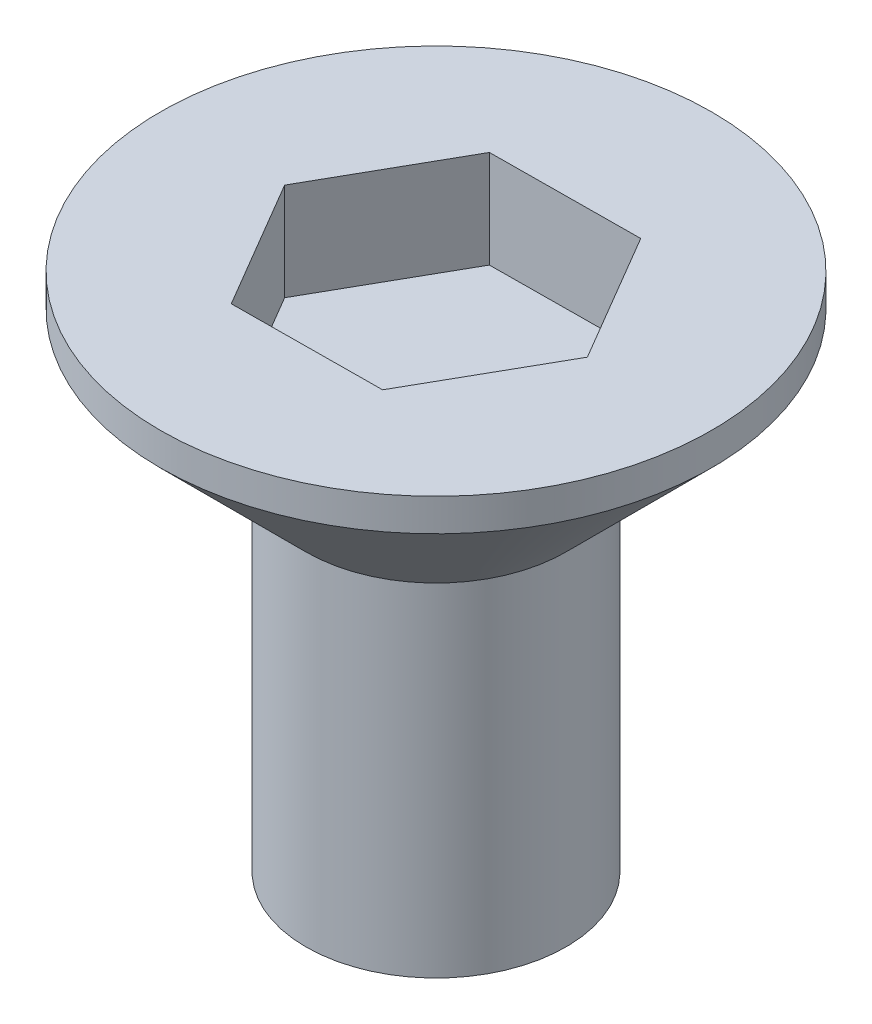
from build123d import *

# Parameters (mm, degrees)
CUT_EXTRUDE_1_DEPTH = 3


with BuildPart() as part:
    # Эскиз1 → Повернуть1 (revolve)
    with BuildSketch(Plane.XY):
        Polygon((0, 0), (4, 0), (4, 10.519431445), (8.480568555, 15), (8.480568555, 16), (0, 16), align=None)
    revolve(axis=Axis((0, 68.644575989, 0), (0, -1, 0)))

    # Эскиз2 → Вырез-Вытянуть1 (cut)
    with BuildSketch(Plane(origin=(0, 16, 0), x_dir=(1, 0, 0), z_dir=(0, 1, 0))):
        Polygon((2.340353871, -3.981968997), (4.618663244, 0.035821408), (2.278309373, 4.017790405), (-2.340353871, 3.981968997), (-4.618663244, -0.035821408), (-2.278309373, -4.017790405), align=None)
    extrude(amount=-CUT_EXTRUDE_1_DEPTH, mode=Mode.SUBTRACT)


solid = part.part
